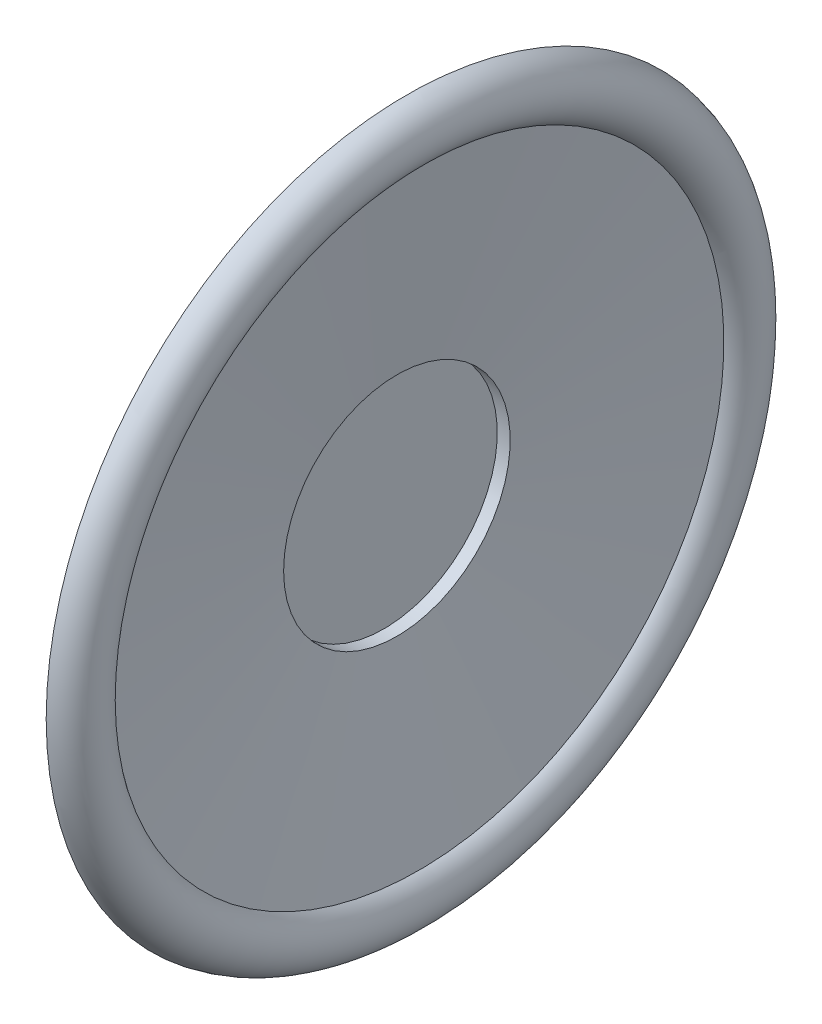
from build123d import *


with BuildPart() as part:
    # Sketch1 → Revolve-Thin3 (revolve)
    with BuildSketch(Plane(origin=(0, 0, 0), x_dir=(1, 0, 0), z_dir=(0, 1, 0))):
        with BuildLine():
            Line((-0.794424497, -7), (-0.794424497, 0))
            Line((-0.794424497, 0), (0, 0))
            Line((0, 0), (1.142372775, 9.900564049))
            ThreePointArc((1.142372775, 9.900564049), (1.801141725, 10.423035974), (1.278669799, 11.081804924))
            Line((1.278669799, 11.081804924), (1.393293907, 12.07521386))
            ThreePointArc((1.393293907, 12.07521386), (2.765201716, 10.845477658), (2.061567501, 9.142750125))
            Line((2.061567501, 9.142750125), (0.891250179, -1))
            Line((0.891250179, -1), (0.205575503, -1))
            Line((0.205575503, -1), (0.205575503, -7))
            Line((0.205575503, -7), (-0.794424497, -7))
        make_face()
    revolve(axis=Axis((-0.794424497, 0, 7), (1, 0, 0)))


solid = part.part
